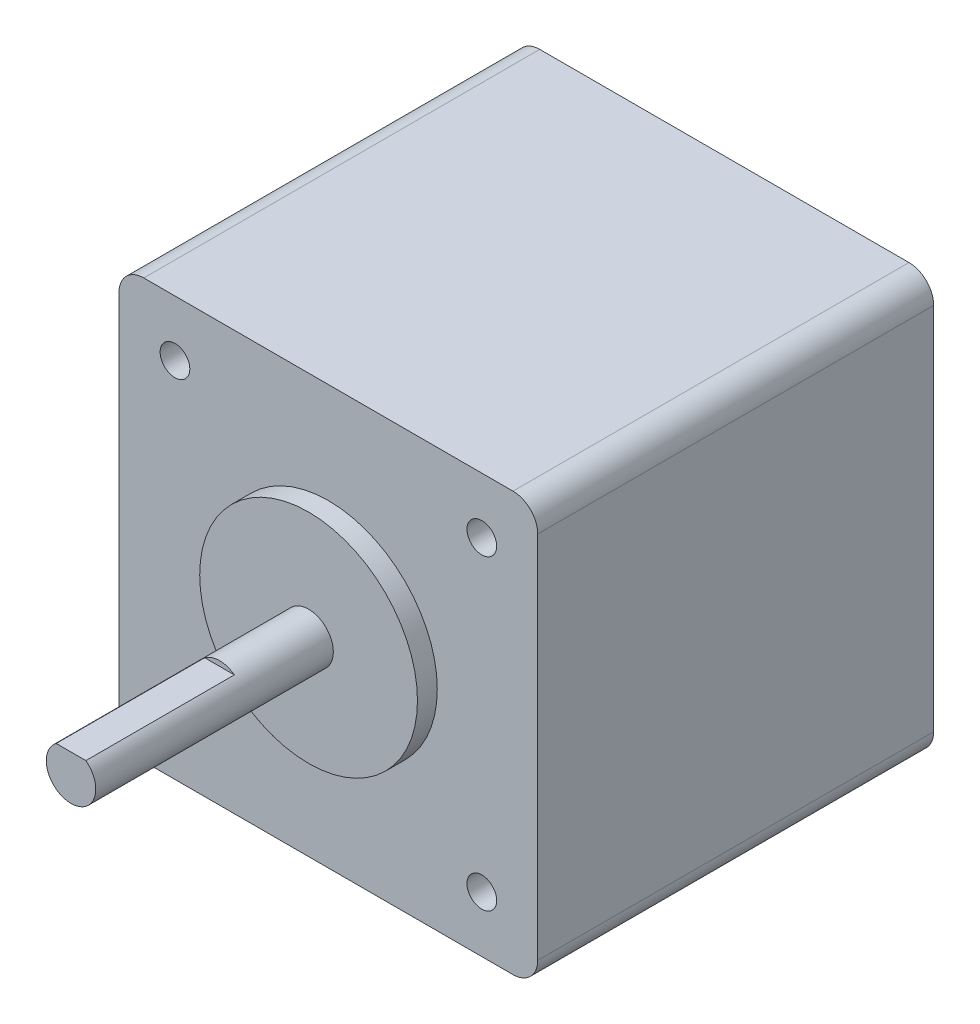
from build123d import *

# Parameters (mm, degrees)
ESBO_O1_W                = 42.3
ESBO_O1_H                = 42.3
RESSALTO_EXTRUS_O1_DEPTH = 40
FILETE1_R                = 2.5
ESBO_O2_R                = 1.5
CORTE_EXTRUS_O2_DEPTH    = 4.5
ESBO_O3_R                = 11
RESSALTO_EXTRUS_O2_DEPTH = 2
ESBO_O4_R                = 2.5
RESSALTO_EXTRUS_O3_DEPTH = 24
ESBO_O5_W                = 8
ESBO_O5_H                = 1
CORTE_EXTRUS_O3_DEPTH    = 15


with BuildPart() as part:
    # Esboço1 → Ressalto-extrusão1 (new body)
    with BuildSketch(Plane.XY):
        Rectangle(ESBO_O1_W, ESBO_O1_H)
    extrude(amount=RESSALTO_EXTRUS_O1_DEPTH)

    # Filete1
    filete1_edges = [part.edges().sort_by_distance(p)[0] for p in [
        (-21.15, 21.15, 20),
        (21.15, 21.15, 20),
        (21.15, -21.15, 20),
        (-21.15, -21.15, 20),
    ]]
    fillet(filete1_edges, radius=FILETE1_R)

    # Esboço2 → Corte-extrusão2 (cut)
    with BuildSketch(Plane.XY.offset(40)):
        with Locations((-15.5, 15.5)):
            Circle(ESBO_O2_R)
        with Locations((15.5, 15.5)):
            Circle(ESBO_O2_R)
        with Locations((15.5, -15.5)):
            Circle(ESBO_O2_R)
        with Locations((-15.5, -15.5)):
            Circle(ESBO_O2_R)
    extrude(amount=-CORTE_EXTRUS_O2_DEPTH, mode=Mode.SUBTRACT)

    # Esboço3 → Ressalto-extrusão2 (add)
    with BuildSketch(Plane.XY.offset(40)):
        Circle(ESBO_O3_R)
    extrude(amount=RESSALTO_EXTRUS_O2_DEPTH)

    # Esboço4 → Ressalto-extrusão3 (add)
    with BuildSketch(Plane.XY.offset(42)):
        Circle(ESBO_O4_R)
    extrude(amount=RESSALTO_EXTRUS_O3_DEPTH)

    # Esboço5 → Corte-extrusão3 (cut)
    with BuildSketch(Plane.XY.offset(66)):
        with Locations((0, 2.5)):
            Rectangle(ESBO_O5_W, ESBO_O5_H)
    extrude(amount=-CORTE_EXTRUS_O3_DEPTH, mode=Mode.SUBTRACT)


solid = part.part
